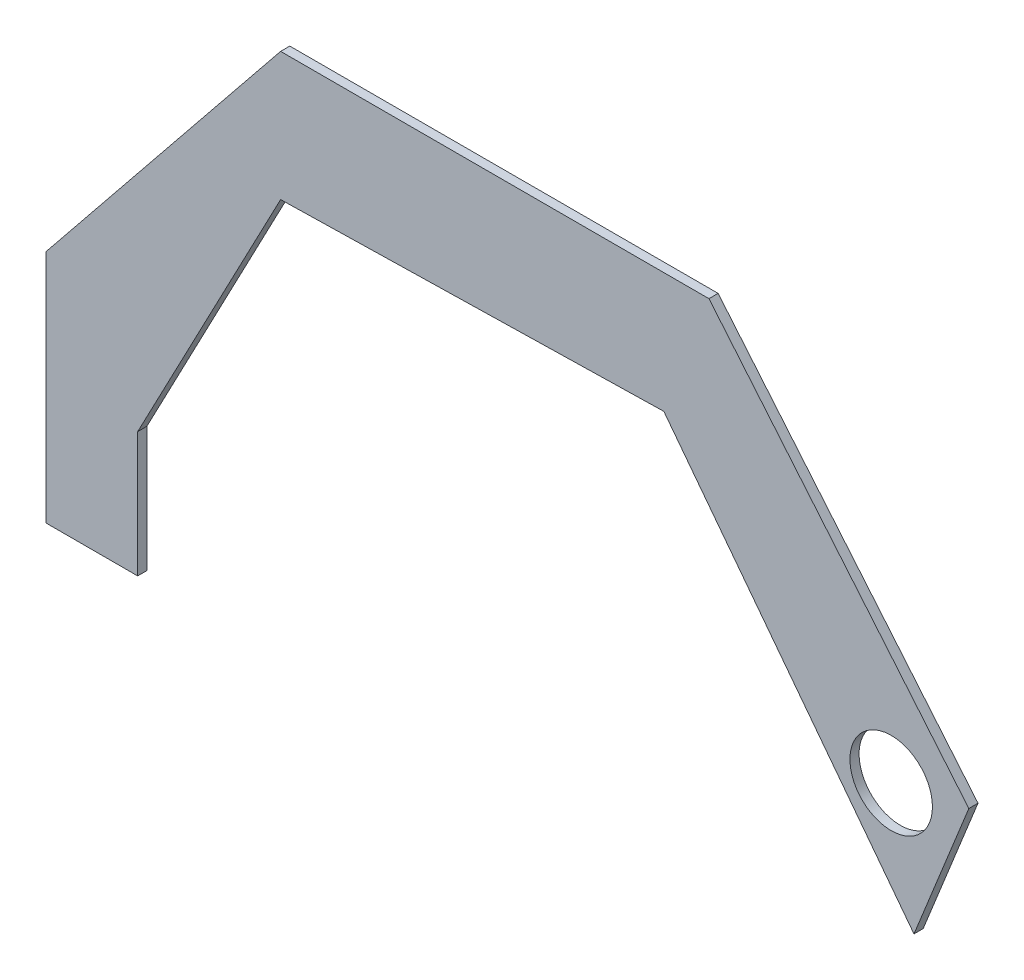
from build123d import *

# Parameters (mm, degrees)
BOSS_EXTRUDE2_DEPTH = 3.175
SKETCH2_R           = 14.2875
CUT_EXTRUDE1_DEPTH  = 3.175


with BuildPart() as part:
    # Sketch1 → Boss-Extrude2 (new body)
    with BuildSketch(Plane.XY):
        Polygon((-154.009419924, 151.208038155), (-235.260882618, 50.510477833), (-235.260882618, -30.875508962), (-203.510882618, -30.875508962), (-203.510882618, 12.410477833), (-154.009419924, 106.758038155), (-21.283324035, 109.590995301), (65.333873999, -3.821796775), (84.327058491, 43.294006761), (-5.668451505, 151.208038155), align=None)
    extrude(amount=BOSS_EXTRUDE2_DEPTH)

    # Sketch2 → Cut-Extrude1 (cut)
    with BuildSketch(Plane.XY.offset(3.175)):
        with Locations((57.432504825, 37.497148832)):
            Circle(SKETCH2_R)
    extrude(amount=-CUT_EXTRUDE1_DEPTH, mode=Mode.SUBTRACT)


solid = part.part
